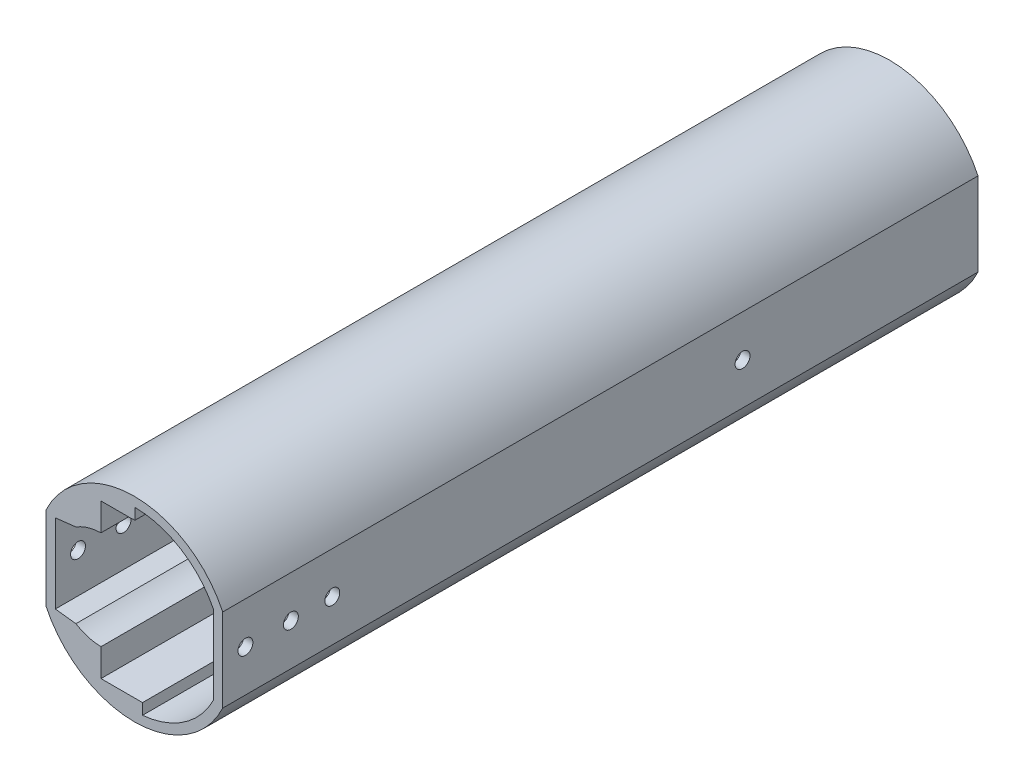
from build123d import *

# Parameters (mm, degrees)
BOSS_EXTRUDE2_DEPTH = 95
BOSS_EXTRUDE3_DEPTH = 95
CUT_EXTRUDE1_DEPTH  = 96
BOSS_EXTRUDE4_DEPTH = 20
BOSS_EXTRUDE5_DEPTH = 45
BOSS_EXTRUDE6_DEPTH = 2
SKETCH7_R           = 6.2
CUT_EXTRUDE2_DEPTH  = 163
SKETCH10_R          = 1.6
CUT_EXTRUDE4_DEPTH  = 38.899923452
SKETCH12_R          = 1.6
BOSS_EXTRUDE8_DEPTH = 2


with BuildPart() as part:
    # Sketch1 → Boss-Extrude2 (new body)
    with BuildSketch(Plane.XY):
        with BuildLine():
            Line((-20.699923452, 8.883949337), (-20.699923452, -8.982202672))
            ThreePointArc((-20.699923452, -8.982202672), (-1.749961726, -20.999088393), (17.2, -8.982202672))
            Line((17.2, -8.982202672), (17.2, 8.883949337))
            ThreePointArc((17.2, 8.883949337), (-1.749961726, 20.900835059), (-20.699923452, 8.883949337))
        make_face()
        with BuildLine():
            ThreePointArc((-18.699923452, -8.522605699), (-1.749961726, -18.999088393), (15.2, -8.522605699))
            Line((15.2, -8.522605699), (15.2, 8.424352365))
            ThreePointArc((15.2, 8.424352365), (-1.749961726, 18.900835059), (-18.699923452, 8.424352365))
            Line((-18.699923452, 8.424352365), (-18.699923452, -8.522605699))
        make_face(mode=Mode.SUBTRACT)
    extrude(amount=-BOSS_EXTRUDE2_DEPTH)

    # Sketch2 → Boss-Extrude3 (add)
    with BuildSketch(Plane.XY):
        with BuildLine():
            ThreePointArc((-14.278781058, 8.932450877), (-11.703080294, 10.091143081), (-8.912, 10.523199609))
            Line((-8.912, 10.523199609), (-8.912, 16.25))
            Line((-8.912, 16.25), (-8.912, 16.45))
            Line((-8.912, 16.45), (-8.712, 16.45))
            Line((-8.712, 16.45), (-3.6, 16.45))
            Line((-3.6, 16.45), (7.570975385, 16.45))
            ThreePointArc((7.570975385, 16.45), (-7.286500278, 18.074001934), (-18.699923452, 8.424352365))
            Line((-18.699923452, 8.424352365), (-14.278781058, 8.932450877))
        make_face()
        with BuildLine():
            Line((-8.912, -16.25), (-8.912, -10.621452943))
            ThreePointArc((-8.912, -10.621452943), (-11.703080294, -10.189396416), (-14.278781058, -9.030704211))
            Line((-14.278781058, -9.030704211), (-18.699923452, -8.522605699))
            ThreePointArc((-18.699923452, -8.522605699), (-7.286500278, -18.172255268), (7.570975385, -16.548253334))
            Line((7.570975385, -16.548253334), (-3.6, -16.548253334))
            Line((-3.6, -16.548253334), (-8.712, -16.548253334))
            Line((-8.712, -16.548253334), (-8.912, -16.548253334))
            Line((-8.912, -16.548253334), (-8.912, -16.25))
        make_face()
    extrude(amount=-BOSS_EXTRUDE3_DEPTH)

    # Sketch3 → Cut-Extrude1 (cut, through all)
    with BuildSketch(Plane.XY):
        with BuildLine():
            Line((7.570975385, -16.548253334), (0, -16.548253334))
            Line((0, -16.548253334), (0, -18.918114011))
            ThreePointArc((0, -18.918114011), (3.910891582, -18.133810498), (7.570975385, -16.548253334))
        make_face()
        with BuildLine():
            ThreePointArc((7.570975385, 16.45), (3.141398236, 18.258676236), (-1.6, 18.900241684))
            Line((-1.6, 18.900241684), (-1.6, 16.45))
            Line((-1.6, 16.45), (7.570975385, 16.45))
        make_face()
    extrude(amount=-CUT_EXTRUDE1_DEPTH, mode=Mode.SUBTRACT)

    # Sketch4 → Boss-Extrude4 (add)
    with BuildSketch(Plane.XY):
        with BuildLine():
            Line((-20.699923452, 8.883949337), (-20.699923452, -8.982202672))
            ThreePointArc((-20.699923452, -8.982202672), (-1.749961726, -20.999088393), (17.2, -8.982202672))
            Line((17.2, -8.982202672), (17.2, 8.883949337))
            ThreePointArc((17.2, 8.883949337), (-1.749961726, 20.900835059), (-20.699923452, 8.883949337))
        make_face()
        with BuildLine():
            Line((-18.699923452, -8.522605699), (-14.278781058, -9.030704211))
            ThreePointArc((-14.278781058, -9.030704211), (-11.703080294, -10.189396416), (-8.912, -10.621452943))
            Line((-8.912, -10.621452943), (-8.912, -16.548253334))
            Line((-8.912, -16.548253334), (0, -16.548253334))
            Line((0, -16.548253334), (0, -18.918114011))
            ThreePointArc((0, -18.918114011), (8.947628308, -15.690821488), (15.2, -8.522605699))
            Line((15.2, -8.522605699), (15.2, 8.424352365))
            ThreePointArc((15.2, 8.424352365), (8.276897691, 16.030771953), (-1.6, 18.900241684))
            Line((-1.6, 18.900241684), (-1.6, 16.45))
            Line((-1.6, 16.45), (-8.912, 16.45))
            Line((-8.912, 16.45), (-8.912, 10.523199609))
            ThreePointArc((-8.912, 10.523199609), (-11.703080294, 10.091143081), (-14.278781058, 8.932450877))
            Line((-14.278781058, 8.932450877), (-18.699923452, 8.424352365))
            Line((-18.699923452, 8.424352365), (-18.699923452, -8.522605699))
        make_face(mode=Mode.SUBTRACT)
    extrude(amount=BOSS_EXTRUDE4_DEPTH)

    # Sketch5 → Boss-Extrude5 (add)
    with BuildSketch(Plane(origin=(0, 0, -95), x_dir=(-1, 0, 0), z_dir=(0, 0, -1))):
        with BuildLine():
            Line((20.699923452, -8.982202672), (20.699923452, 8.883949337))
            ThreePointArc((20.699923452, 8.883949337), (1.749961726, 20.900835059), (-17.2, 8.883949337))
            Line((-17.2, 8.883949337), (-17.2, -8.982202672))
            ThreePointArc((-17.2, -8.982202672), (1.749961726, -20.999088393), (20.699923452, -8.982202672))
        make_face()
        with BuildLine():
            Line((-15.2, 8.424352365), (-15.2, -8.522605699))
            ThreePointArc((-15.2, -8.522605699), (-8.947628308, -15.690821488), (0, -18.918114011))
            Line((0, -18.918114011), (0, -16.548253334))
            Line((0, -16.548253334), (8.912, -16.548253334))
            Line((8.912, -16.548253334), (8.912, -10.621452943))
            ThreePointArc((8.912, -10.621452943), (11.703080294, -10.189396416), (14.278781058, -9.030704211))
            Line((14.278781058, -9.030704211), (18.699923452, -8.522605699))
            Line((18.699923452, -8.522605699), (18.699923452, 8.424352365))
            Line((18.699923452, 8.424352365), (14.278781058, 8.932450877))
            ThreePointArc((14.278781058, 8.932450877), (11.703080294, 10.091143081), (8.912, 10.523199609))
            Line((8.912, 10.523199609), (8.912, 16.45))
            Line((8.912, 16.45), (1.6, 16.45))
            Line((1.6, 16.45), (1.6, 18.900241684))
            ThreePointArc((1.6, 18.900241684), (-8.276897691, 16.030771953), (-15.2, 8.424352365))
        make_face(mode=Mode.SUBTRACT)
    extrude(amount=BOSS_EXTRUDE5_DEPTH)

    # Sketch6 → Boss-Extrude6 (add)
    with BuildSketch(Plane(origin=(0, 0, -140), x_dir=(-1, 0, 0), z_dir=(0, 0, -1))):
        with BuildLine():
            Line((20.699923452, -8.982202672), (20.699923452, 8.883949337))
            ThreePointArc((20.699923452, 8.883949337), (1.749961726, 20.900835059), (-17.2, 8.883949337))
            Line((-17.2, 8.883949337), (-17.2, -8.982202672))
            ThreePointArc((-17.2, -8.982202672), (1.749961726, -20.999088393), (20.699923452, -8.982202672))
        make_face()
    extrude(amount=BOSS_EXTRUDE6_DEPTH)

    # Sketch7 → Cut-Extrude2 (cut, through all)
    with BuildSketch(Plane(origin=(0, 0, -142), x_dir=(-1, 0, 0), z_dir=(0, 0, -1))):
        with BuildLine():
            ThreePointArc((0.364575498, 16.400766737), (-4.6, 10.3251), (0.364575498, 4.249433263))
            Line((0.364575498, 4.249433263), (0.364575498, 16.400766737))
        make_face()
        with BuildLine():
            Line((0.364575498, 16.400766737), (0.364575498, 4.249433263))
            ThreePointArc((0.364575498, 4.249433263), (5.523032506, 5.524077613), (7.8, 10.3251))
            ThreePointArc((7.8, 10.3251), (5.523032506, 15.126122387), (0.364575498, 16.400766737))
        make_face()
        with Locations((1.6, -8.707225505)):
            Circle(SKETCH7_R)
    extrude(amount=-CUT_EXTRUDE2_DEPTH, mode=Mode.SUBTRACT)

    # Sketch10 → Cut-Extrude4 (cut, through all)
    with BuildSketch(Plane(origin=(17.2, 0, 0), x_dir=(0, 0, -1), z_dir=(1, 0, 0))):
        with Locations((91.5, -0.049126667)):
            Circle(SKETCH10_R)
        with Locations((3.5, -0.049126667)):
            Circle(SKETCH10_R)
        with Locations((-5.375, -0.049126667)):
            Circle(SKETCH10_R)
        with Locations((-15.125, -0.024563334)):
            Circle(SKETCH10_R)
    extrude(amount=-CUT_EXTRUDE4_DEPTH, mode=Mode.SUBTRACT)

    # Sketch12 → Boss-Extrude8 (add)
    with BuildSketch(Plane.ZY.offset(20.699923452)):
        with Locations((-91.5, -0.049126667)):
            Circle(SKETCH12_R)
        with Locations((-3.5, -0.049126667)):
            Circle(SKETCH12_R)
    extrude(amount=-BOSS_EXTRUDE8_DEPTH)


solid = part.part
